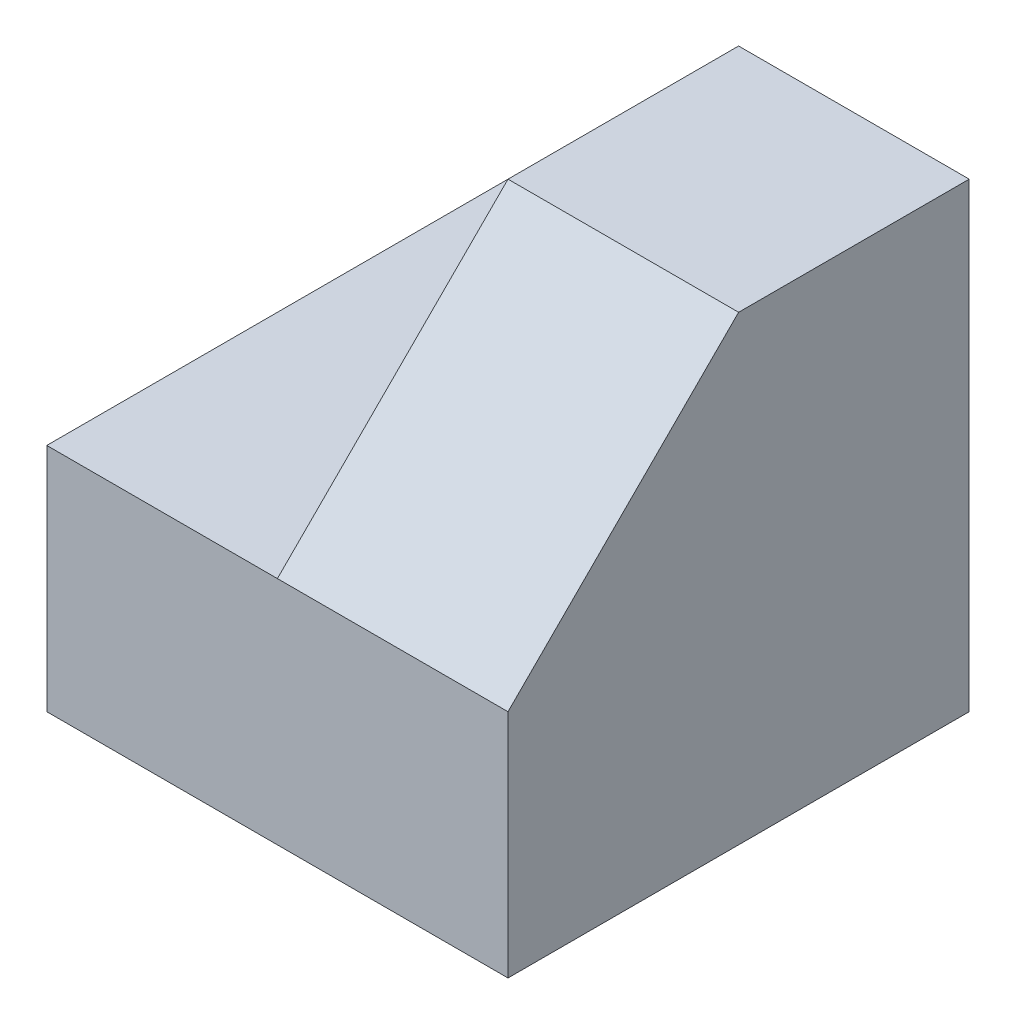
from build123d import *

# Parameters (mm, degrees)
SKETCH1_W           = 40
SKETCH1_H           = 40
BOSS_EXTRUDE1_DEPTH = 40
SKETCH2_W           = 20
SKETCH2_H           = 20
CUT_EXTRUDE1_DEPTH  = 40
CUT_EXTRUDE2_DEPTH  = 40


with BuildPart() as part:
    # Sketch1 → Boss-Extrude1 (new body)
    with BuildSketch(Plane.XY):
        with Locations((20, 20)):
            Rectangle(SKETCH1_W, SKETCH1_H)
    extrude(amount=BOSS_EXTRUDE1_DEPTH)

    # Sketch2 → Cut-Extrude1 (cut)
    with BuildSketch(Plane.XY.offset(40)):
        with Locations((10, 30)):
            Rectangle(SKETCH2_W, SKETCH2_H)
    extrude(amount=-CUT_EXTRUDE1_DEPTH, mode=Mode.SUBTRACT)

    # Sketch3 → Cut-Extrude2 (cut)
    with BuildSketch(Plane.ZY.offset(-20)):
        Polygon((20, 40), (40, 20), (40, 40), align=None)
    extrude(amount=-CUT_EXTRUDE2_DEPTH, mode=Mode.SUBTRACT)


solid = part.part
